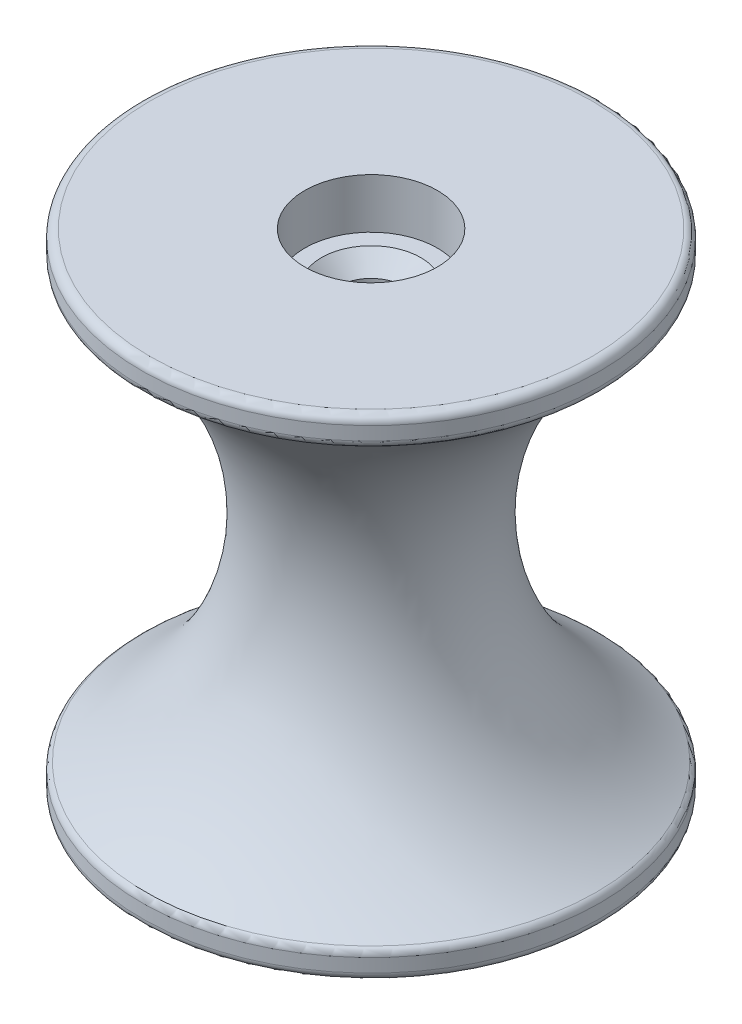
from build123d import *

# Parameters (mm, degrees)
FILLET1_R = 0.79375


with BuildPart() as part:
    # Sketch1 → Revolve1 (revolve)
    with BuildSketch(Plane.XY):
        with BuildLine():
            Line((-6.35, 23.490258671), (-21.969306582, 23.490258671))
            Line((-21.969306582, 23.490258671), (-21.969306582, 20.950258671))
            ThreePointArc((-21.969306582, 20.950258671), (-13.025892187, 12.127448299), (-9.746922584, 0))
            ThreePointArc((-9.746922584, 0), (-13.025892187, -12.127448299), (-21.969306582, -20.950258671))
            Line((-21.969306582, -20.950258671), (-21.969306582, -23.490258671))
            Line((-21.969306582, -23.490258671), (-6.35, -23.490258671))
            Line((-6.35, -23.490258671), (-6.35, -18.715058671))
            Line((-6.35, -18.715058671), (-4.7625, -18.715058671))
            Line((-4.7625, -18.715058671), (-3.175, -17.127558671))
            Line((-3.175, -17.127558671), (-3.175, 17.127558671))
            Line((-3.175, 17.127558671), (-4.7625, 18.715058671))
            Line((-4.7625, 18.715058671), (-6.35, 18.715058671))
            Line((-6.35, 18.715058671), (-6.35, 23.490258671))
        make_face()
    revolve(axis=Axis((0, 23.490258671, 0), (0, -1, 0)))

    # Fillet1
    fillet1_edges = [part.edges().sort_by_distance(p)[0] for p in [
        (21.969306582, 20.950258671, 0),
        (21.969306582, 23.490258671, 0),
        (21.969306582, -23.490258671, 0),
        (21.969306582, -20.950258671, 0),
    ]]
    fillet(fillet1_edges, radius=FILLET1_R)


solid = part.part
